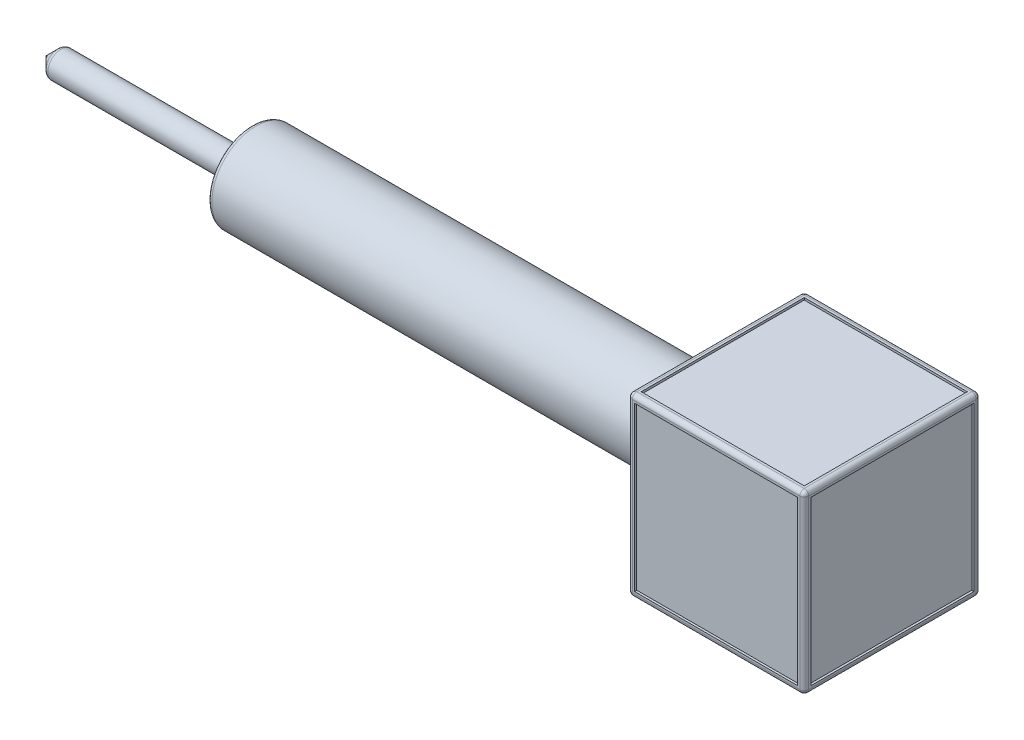
from build123d import *

# Parameters (mm, degrees)
SKETCH2_W                = 40
SKETCH2_H                = 40
BOSS_EXTRUDE1_DEPTH      = 20
BOSS_EXTRUDE1_DEPTH_BACK = 20
FILLET2_R                = 1
FILLET3_R                = 1
SKETCH3_W                = 37
SKETCH3_H                = 37
CUT_EXTRUDE1_DEPTH       = 0.5
CIRPATTERN1_COUNT        = 4
CIRPATTERN3_COUNT        = 2
CIRPATTERN3_ANGLE        = 90


with BuildPart() as part:
    # Sketch1 → Revolve1 (revolve)
    with BuildSketch(Plane.XY):
        with BuildLine():
            Line((0, 0), (180, 0))
            Line((180, 0), (180, 2))
            ThreePointArc((180, 2), (177.656854249, 7.656854249), (172, 10))
            Line((172, 10), (61.659544264, 10))
            Line((61.659544264, 10), (47.041451884, 10))
            Line((47.041451884, 10), (43, 3))
            Line((43, 3), (3, 3))
            Line((3, 3), (0, 0))
        make_face()
    revolve(axis=Axis((0, 0, 0), (1, 0, 0)))

    # Sketch2 → Boss-Extrude1 (add, two sides)
    with BuildSketch(Plane.XY) as boss_extrude1_sk:
        with Locations((172, 0)):
            Rectangle(SKETCH2_W, SKETCH2_H)
    extrude(amount=BOSS_EXTRUDE1_DEPTH)
    extrude(boss_extrude1_sk.sketch, amount=-BOSS_EXTRUDE1_DEPTH_BACK)

    # Fillet2
    fillet2_edges = [part.edges().sort_by_distance(p)[0] for p in [
        (152, -10, 0),
        (192, 20, 0),
        (192, 0, -20),
        (192, -20, 0),
        (172, -20, -20),
        (152, -20, 0),
        (152, 0, -20),
        (152, 20, 0),
        (172, 20, -20),
        (192, 0, 20),
        (172, 20, 20),
        (152, 0, 20),
        (172, -20, 20),
    ]]
    fillet(fillet2_edges, radius=FILLET2_R)

    # Fillet3
    fillet3_edges = [part.edges().sort_by_distance(p)[0] for p in [
        (3, -3, 0),
        (43, -3, 0),
        (47.041451884, -10, 0),
    ]]
    fillet(fillet3_edges, radius=FILLET3_R)

    # Sketch3 → Cut-Extrude1 (cut)
    with BuildSketch(Plane(origin=(0, 0, -20), x_dir=(-1, 0, 0), z_dir=(0, 0, -1))):
        with Locations((-172, 0)):
            Rectangle(SKETCH3_W, SKETCH3_H)
    cut_extrude1 = extrude(amount=-CUT_EXTRUDE1_DEPTH, mode=Mode.SUBTRACT)

    # CirPattern1: Cut-Extrude1 ×4 about axis
    cirpattern1_axis = Axis((0, 0, 0), (1, 0, 0))
    for i in range(1, CIRPATTERN1_COUNT):
        add(cut_extrude1.rotate(cirpattern1_axis, i * 360 / CIRPATTERN1_COUNT), mode=Mode.SUBTRACT)

    # CirPattern3: Cut-Extrude1 ×2 about axis
    cirpattern3_axis = Axis((172, 0, 0), (0, -1, 0))
    for i in range(1, CIRPATTERN3_COUNT):
        add(cut_extrude1.rotate(cirpattern3_axis, i * CIRPATTERN3_ANGLE / (CIRPATTERN3_COUNT - 1)), mode=Mode.SUBTRACT)


solid = part.part
